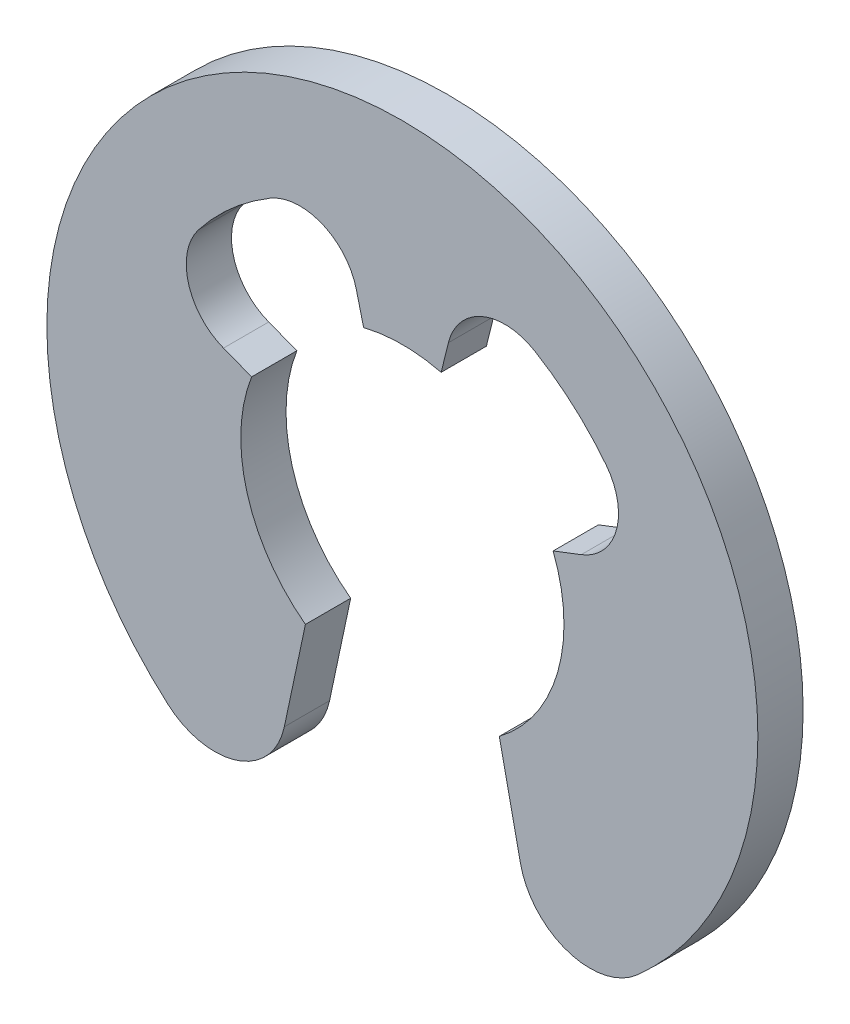
from build123d import *

# Parameters (mm, degrees)
BOSS_EXTRU_1_DEPTH = 0.7


with BuildPart() as part:
    # Esquisse1 → Boss.-Extru.1 (new body)
    with BuildSketch(Plane.XY):
        with BuildLine():
            Line((-1.5, -2), (-1.826421175, -3.535690887))
            ThreePointArc((-1.826421175, -3.535690887), (-2.555824208, -4.350969173), (-3.627979419, -4.133735034))
            ThreePointArc((-3.627979419, -4.133735034), (0, 5.5), (3.627979419, -4.133735034))
            ThreePointArc((3.627979419, -4.133735034), (2.555824208, -4.350969173), (1.826421175, -3.535690887))
            Line((1.826421175, -3.535690887), (1.5, -2))
            ThreePointArc((1.5, -2), (2.402974317, -0.689720546), (2.332380758, 0.9))
            Line((2.332380758, 0.9), (2.767583784, 1.067932582))
            ThreePointArc((2.767583784, 1.067932582), (3.311013995, 1.66766294), (3.153011334, 2.461406006))
            ThreePointArc((3.153011334, 2.461406006), (2.644889885, 3.000759486), (2.046000844, 3.437132605))
            ThreePointArc((2.046000844, 3.437132605), (1.238700066, 3.494214576), (0.711955055, 2.879777769))
            Line((0.711955055, 2.879777769), (0.6, 2.42693222))
            ThreePointArc((0.6, 2.42693222), (0, 2.5), (-0.6, 2.42693222))
            Line((-0.6, 2.42693222), (-0.711955055, 2.879777769))
            ThreePointArc((-0.711955055, 2.879777769), (-1.238700066, 3.494214576), (-2.046000844, 3.437132605))
            ThreePointArc((-2.046000844, 3.437132605), (-2.644889885, 3.000759486), (-3.153011334, 2.461406006))
            ThreePointArc((-3.153011334, 2.461406006), (-3.311013995, 1.66766294), (-2.767583784, 1.067932582))
            Line((-2.767583784, 1.067932582), (-2.332380758, 0.9))
            ThreePointArc((-2.332380758, 0.9), (-2.402974317, -0.689720546), (-1.5, -2))
        make_face()
    extrude(amount=BOSS_EXTRU_1_DEPTH)


solid = part.part
